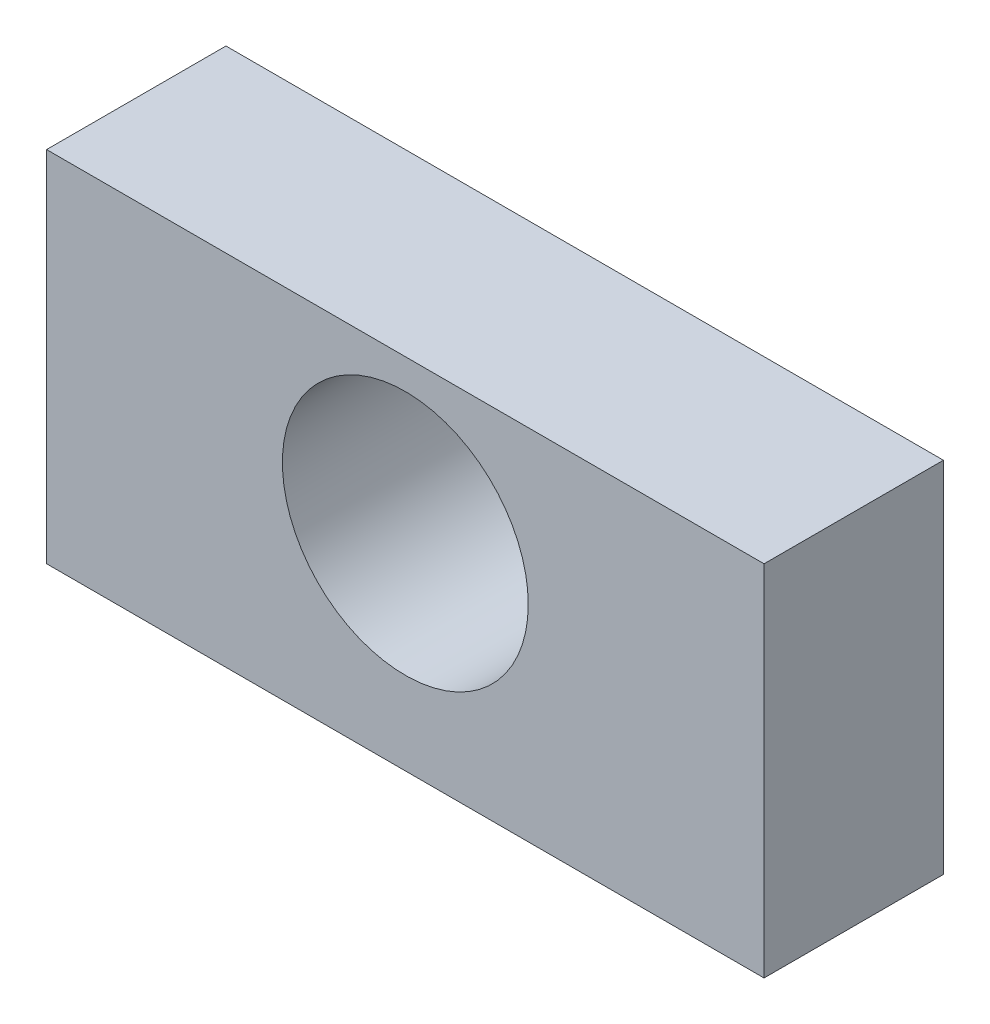
from build123d import *

# Parameters (mm, degrees)
SKETCH1_W                   = 19.05
SKETCH1_H                   = 9.525
EXTRUDE1_DEPTH              = 4.7625
F_1_4_CLEARANCE_HOLE1_D     = 6.5278
F_1_4_CLEARANCE_HOLE1_DEPTH = 15.24
F_1_4_CLEARANCE_HOLE1_TIP   = 1.961148974


with BuildPart() as part:
    # Sketch1 → Extrude1 (new body)
    with BuildSketch(Plane.XY):
        Rectangle(SKETCH1_W, SKETCH1_H)
    extrude(amount=EXTRUDE1_DEPTH)

    # 1/4 Clearance Hole1
    with Locations(Plane(origin=(0, 0.6985, 4.7625), x_dir=(1, 0, 0), z_dir=(0, 0, 1))):
        with Locations((0, 0)):
            Hole(F_1_4_CLEARANCE_HOLE1_D / 2, depth=F_1_4_CLEARANCE_HOLE1_DEPTH)
            with Locations((0, 0, -(F_1_4_CLEARANCE_HOLE1_DEPTH + F_1_4_CLEARANCE_HOLE1_TIP / 2))):  # 118° drill point
                Cone(0, F_1_4_CLEARANCE_HOLE1_D / 2, F_1_4_CLEARANCE_HOLE1_TIP, mode=Mode.SUBTRACT)


solid = part.part
